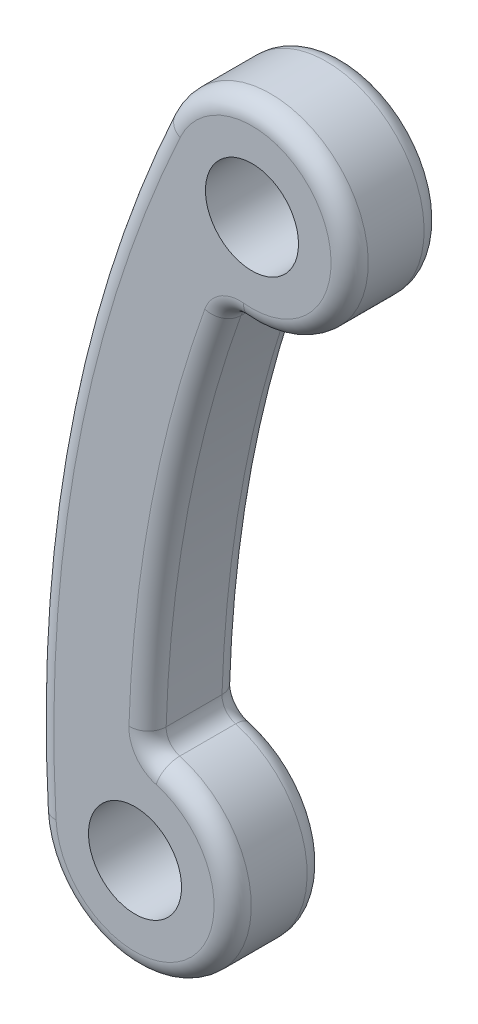
from build123d import *

# Parameters (mm, degrees)
SKETCH2_R           = 5
BOSS_EXTRUDE1_DEPTH = 10
FILLET1_R           = 2


with BuildPart() as part:
    # Sketch2 → Boss-Extrude1 (new body)
    with BuildSketch(Plane.XY):
        with BuildLine():
            ThreePointArc((-136.248221627, 62.740912517), (-147.363336048, 28.000842642), (-149.764900792, -8.394908626))
            ThreePointArc((-149.764900792, -8.394908626), (-132.116158495, -15.482544811), (-137.975293762, 2.611189609))
            ThreePointArc((-137.975293762, 2.611189609), (-135.574269165, 25.760775231), (-129.317107469, 48.177647472))
            ThreePointArc((-129.317107469, 48.177647472), (-117.229857172, 62.861348354), (-136.248221627, 62.740912517))
        make_face()
        with Locations((-126.710846113, 58.349048641)):
            Circle(SKETCH2_R, mode=Mode.SUBTRACT)
        with Locations((-139.281357736, -7.807265022)):
            Circle(SKETCH2_R, mode=Mode.SUBTRACT)
    extrude(amount=BOSS_EXTRUDE1_DEPTH)

    # Fillet1
    fillet1_edges = [part.edges().sort_by_distance(p)[0] for p in [
        (-147.363336048, 28.000842642, 10),
        (-132.116158495, -15.482544811, 10),
        (-135.574269165, 25.760775231, 10),
        (-132.116158495, -15.482544811, 0),
        (-147.363336048, 28.000842642, 0),
        (-117.229857172, 62.861348354, 0),
        (-135.574269165, 25.760775231, 0),
        (-117.229857172, 62.861348354, 10),
        (-137.975293762, 2.611189609, 5),
        (-129.317107469, 48.177647472, 5),
    ]]
    fillet(fillet1_edges, radius=FILLET1_R)


solid = part.part
